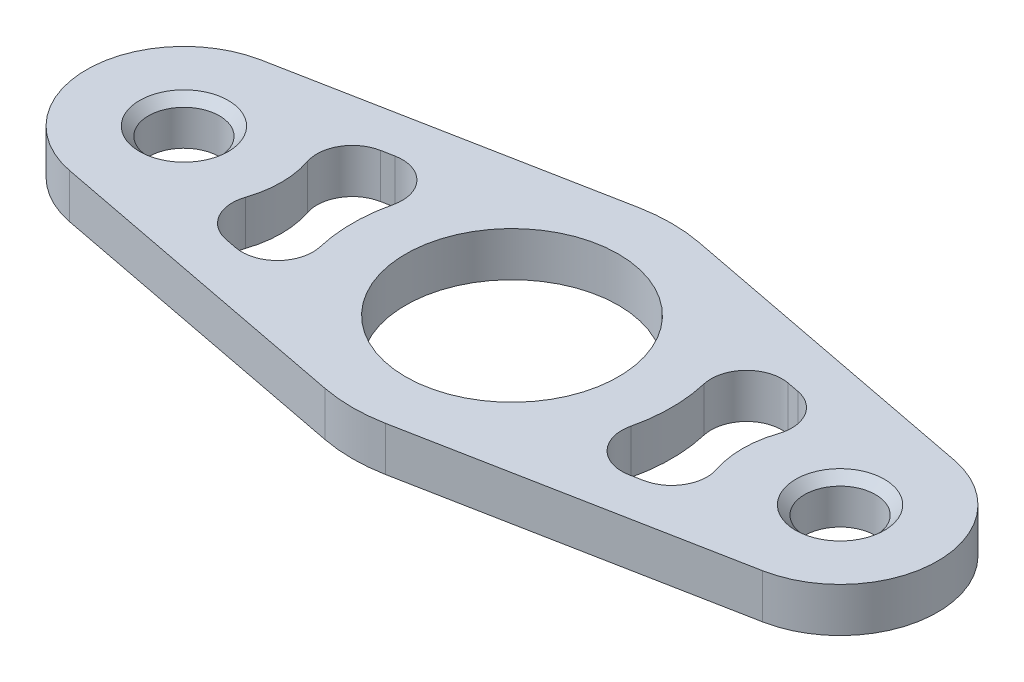
from build123d import *

# Parameters (mm, degrees)
SKETCH1_R           = 4
SKETCH1_R_2         = 12
BOSS_EXTRUDE1_DEPTH = 2.5
FILLET1_R           = 4
CHAMFER1_SIZE       = 1


with BuildPart() as part:
    # Sketch1 → Boss-Extrude1 (new body, symmetric)
    with BuildSketch(Plane(origin=(0, 0, 0), x_dir=(1, 0, 0), z_dir=(0, 1, 0))):
        with BuildLine():
            Line((39.081081081, 10.801347209), (3.405405405, 17.674931797))
            ThreePointArc((3.405405405, 17.674931797), (0, 18), (-3.405405405, 17.674931797))
            Line((-3.405405405, 17.674931797), (-39.081081081, 10.801347209))
            ThreePointArc((-39.081081081, 10.801347209), (-48, 0), (-39.081081081, -10.801347209))
            Line((-39.081081081, -10.801347209), (-3.405405405, -17.674931797))
            ThreePointArc((-3.405405405, -17.674931797), (0, -18), (3.405405405, -17.674931797))
            Line((3.405405405, -17.674931797), (39.081081081, -10.801347209))
            ThreePointArc((39.081081081, -10.801347209), (48, 0), (39.081081081, 10.801347209))
        make_face()
        with Locations((37, 0)):
            Circle(SKETCH1_R, mode=Mode.SUBTRACT)
        with Locations((-37, 0)):
            Circle(SKETCH1_R, mode=Mode.SUBTRACT)
        Circle(SKETCH1_R_2, mode=Mode.SUBTRACT)
        with BuildLine():
            Line((-29.082089608, -7.635882073), (-14.68452203, -10.40984211))
            ThreePointArc((-14.68452203, -10.40984211), (-18, 0), (-14.68452203, 10.40984211))
            Line((-14.68452203, 10.40984211), (-29.082089608, 7.635882073))
            ThreePointArc((-29.082089608, 7.635882073), (-26, 0), (-29.082089608, -7.635882073))
        make_face(mode=Mode.SUBTRACT)
        with BuildLine():
            ThreePointArc((14.68452203, 10.40984211), (18, 0), (14.68452203, -10.40984211))
            Line((14.68452203, -10.40984211), (29.082089608, -7.635882073))
            ThreePointArc((29.082089608, -7.635882073), (26, 0), (29.082089608, 7.635882073))
            Line((29.082089608, 7.635882073), (14.68452203, 10.40984211))
        make_face(mode=Mode.SUBTRACT)
    extrude(amount=BOSS_EXTRUDE1_DEPTH, both=True)

    # Fillet1
    fillet1_edges = [part.edges().sort_by_distance(p)[0] for p in [
        (14.68452203, 0, 10.40984211),
        (29.082089608, 0, 7.635882073),
        (29.082089608, 0, -7.635882073),
        (14.68452203, 0, -10.40984211),
        (-14.68452203, 0, 10.40984211),
        (-14.68452203, 0, -10.40984211),
        (-29.082089608, 0, -7.635882073),
        (-29.082089608, 0, 7.635882073),
    ]]
    fillet(fillet1_edges, radius=FILLET1_R)

    # Chamfer1
    chamfer1_edges = [part.edges().sort_by_distance(p)[0] for p in [
        (33, 2.5, 0),
        (-41, 2.5, 0),
    ]]
    chamfer(chamfer1_edges, length=CHAMFER1_SIZE)


solid = part.part
